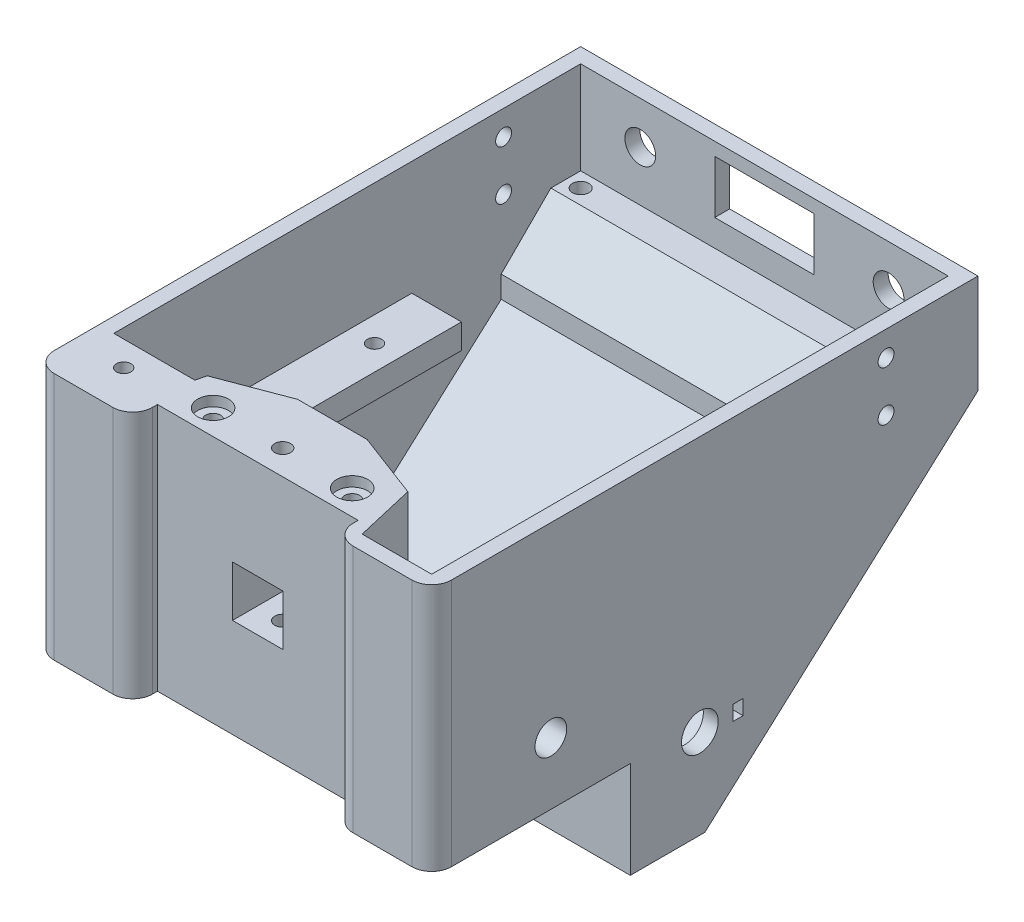
from build123d import *

# Parameters (mm, degrees)
BOSS_EXTRUDE1_DEPTH      = 80
SHELL1_T                 = -3
SKETCH3_W                = 46
SKETCH3_H                = 47
BOSS_EXTRUDE2_DEPTH      = 17
SKETCH4_W                = 10.2
SKETCH4_H                = 10.2
CUT_EXTRUDE1_DEPTH       = 20
SKETCH6_W                = 15
SKETCH6_H                = 12.8
CUT_EXTRUDE2_DEPTH       = 3
SKETCH7_W                = 40.4
SKETCH7_H                = 50
CUT_EXTRUDE3_DEPTH       = 5
FILLET1_R                = 4
CUT_EXTRUDE7_DEPTH       = 47
SKETCH13_R               = 1.5
CUT_EXTRUDE8_DEPTH       = 25
SKETCH14_R               = 3.1
CUT_EXTRUDE9_DEPTH       = 2
SKETCH17_W               = 45
SKETCH17_H               = 5
BOSS_EXTRUDE5_DEPTH      = 74
CUT_EXTRUDE10_REACH      = 126.093
SKETCH18_W               = 54
SKETCH18_H               = 45
CUT_EXTRUDE11_REACH      = 126.093
SKETCH19_R               = 1.45
BOSS_EXTRUDE6_DEPTH      = 47
SKETCH22_R               = 1.45
CUT_EXTRUDE12_DEPTH      = 135.415364765
CUT_EXTRUDE13_REACH      = 126.857
SKETCH24_R               = 3.7
SKETCH24_W               = 2
SKETCH24_H               = 3
BOSS_EXTRUDE7_DEPTH      = 74
SKETCH27_R               = 1.65
CUT_EXTRUDE14_DEPTH      = 10
CUT_EXTRUDE15_START      = -3
CUT_EXTRUDE15_DEPTH      = 32
CUT_EXTRUDE16_DEPTH      = 30
BOSS_EXTRUDE8_DEPTH      = 20
SKETCH31_R               = 1.5
CUT_EXTRUDE17_DEPTH      = 123.649786567
CUT_EXTRUDE18_DEPTH      = 15
CUT_EXTRUDE19_REACH      = 126.093
SKETCH33_W               = 10
SKETCH33_H               = 5
SKETCH34_R               = 1.6
CUT_EXTRUDE20_DEPTH      = 135.415364765
CUT_EXTRUDE22_DEPTH      = 14
CUT_EXTRUDE23_REACH      = 126.857
SKETCH37_R               = 3.2
SKETCH38_W               = 10
SKETCH38_H               = 18.980735551
SKETCH38_R               = 3.2
BOSS_EXTRUDE9_DEPTH      = 3
CUT_EXTRUDE24_REACH      = 124.956
SKETCH40_R               = 3.7
SKETCH40_W               = 2
SKETCH40_H               = 3
SKETCH41_R               = 1.6
CUT_EXTRUDE25_DEPTH      = 123.956316006
CUT_EXTRUDE25_DEPTH_BACK = 123.956316006
SKETCH43_W               = 20
SKETCH43_H               = 10.67
CUT_EXTRUDE26_DEPTH      = 3
CHAMFER1_SIZE            = 10
SKETCH44_R               = 3.1
CUT_EXTRUDE27_DEPTH      = 143.134986308


with BuildPart() as part:
    # Sketch2 → Boss-Extrude1 (new body)
    with BuildSketch(Plane(origin=(0, 0, 0), x_dir=(0, 0, -1), z_dir=(1, 0, 0))):
        Polygon((-27.320490368, 20.998248687), (-27.320490368, -29.001751313), (12.679509632, -29.001751313), (12.679509632, -48.511383538), (27.679509632, -48.511383538), (82.679509632, 0.998248687), (82.679509632, 20.998248687), align=None)
    extrude(amount=BOSS_EXTRUDE1_DEPTH)

    # Shell1
    shell1_openings = [part.faces().sort_by_distance(p)[0] for p in [
        (40, 20.998248687, -27.679509632),
    ]]
    offset(amount=SHELL1_T, openings=shell1_openings, kind=Kind.INTERSECTION)

    # Sketch3 → Boss-Extrude2 (add)
    with BuildSketch(Plane(origin=(0, 0, 24.320490368), x_dir=(-1, 0, 0), z_dir=(0, 0, -1))):
        with Locations((-40, -2.501751313)):
            Rectangle(SKETCH3_W, SKETCH3_H)
    extrude(amount=BOSS_EXTRUDE2_DEPTH)

    # Sketch4 → Cut-Extrude1 (cut)
    with BuildSketch(Plane.XY.offset(27.320490368)):
        with Locations((40, -4.001751313)):
            Rectangle(SKETCH4_W, SKETCH4_H)
    extrude(amount=-CUT_EXTRUDE1_DEPTH, mode=Mode.SUBTRACT)

    # Sketch6 → Cut-Extrude2 (cut)
    with BuildSketch(Plane.XZ.offset(29.001751313)):
        with Locations((51.5, 0.920490368)):
            Rectangle(SKETCH6_W, SKETCH6_H)
        with Locations((28.5, 0.920490368)):
            Rectangle(SKETCH6_W, SKETCH6_H)
    extrude(amount=-CUT_EXTRUDE2_DEPTH, mode=Mode.SUBTRACT)

    # Sketch7 → Cut-Extrude3 (cut)
    with BuildSketch(Plane.XY.offset(27.320490368)):
        with Locations((40, -4.001751313)):
            Rectangle(SKETCH7_W, SKETCH7_H)
    extrude(amount=-CUT_EXTRUDE3_DEPTH, mode=Mode.SUBTRACT)

    # Fillet1
    fillet1_edges = [part.edges().sort_by_distance(p)[0] for p in [
        (19.8, -4.001751313, 27.320490368),
        (60.2, -4.001751313, 27.320490368),
        (80, -4.001751313, 27.320490368),
        (0, -4.001751313, 27.320490368),
    ]]
    fillet(fillet1_edges, radius=FILLET1_R)

    # Sketch12 → Cut-Extrude7 (cut)
    with BuildSketch(Plane(origin=(0, 20.998248687, 0), x_dir=(1, 0, 0), z_dir=(0, 1, 0))):
        Polygon((33, -7.320490368), (19.8, -12.320490368), (17, -24.320490368), (17, -7.320490368), align=None)
        Polygon((47, -7.320490368), (63, -7.320490368), (63, -24.320490368), (60.2, -12.320490368), align=None)
    extrude(amount=-CUT_EXTRUDE7_DEPTH, mode=Mode.SUBTRACT)

    # Sketch13 → Cut-Extrude8 (cut)
    with BuildSketch(Plane(origin=(0, 20.998248687, 0), x_dir=(1, 0, 0), z_dir=(0, 1, 0))):
        with Locations(Location((26, -17.320490368, 0), (0, 0, 270))):
            Circle(SKETCH13_R)
        with Locations(Location((54, -17.320490368, 0), (0, 0, 270))):
            Circle(SKETCH13_R)
    extrude(amount=-CUT_EXTRUDE8_DEPTH, mode=Mode.SUBTRACT)

    # Sketch14 → Cut-Extrude9 (cut)
    with BuildSketch(Plane(origin=(0, 20.998248687, 0), x_dir=(1, 0, 0), z_dir=(0, 1, 0))):
        with Locations(Location((26, -17.320490368, 0), (0, 0, 270))):
            Circle(SKETCH14_R)
        with Locations(Location((54, -17.320490368, 0), (0, 0, 270))):
            Circle(SKETCH14_R)
    extrude(amount=-CUT_EXTRUDE9_DEPTH, mode=Mode.SUBTRACT)

    # Sketch17 → Boss-Extrude5 (add)
    with BuildSketch(Plane.ZY.offset(-77)):
        with Locations((-23.179509632, -4.501751313)):
            Rectangle(SKETCH17_W, SKETCH17_H)
    extrude(amount=BOSS_EXTRUDE5_DEPTH)

    # Sketch18 → Cut-Extrude10 (cut, up to next)
    with BuildSketch(Plane(origin=(0, -2.001751313, 0), x_dir=(1, 0, 0), z_dir=(0, 1, 0)), mode=Mode.PRIVATE) as cut_extrude10_sk1:
        with Locations((40, 23.179509632)):
            Rectangle(SKETCH18_W, SKETCH18_H)
    cut_extrude10_tool1 = extrude(cut_extrude10_sk1.sketch, amount=-CUT_EXTRUDE10_REACH, mode=Mode.PRIVATE) & part.part
    add(cut_extrude10_tool1.solids().sort_by_distance((40, -2.001751, -23.17951))[0], mode=Mode.SUBTRACT)

    # Sketch19 → Cut-Extrude11 (cut, up to next)
    with BuildSketch(Plane(origin=(0, -2.001751313, 0), x_dir=(1, 0, 0), z_dir=(0, 1, 0)), mode=Mode.PRIVATE) as cut_extrude11_sk1:
        with Locations(Location((72, 37.179509632, 0), (0, 0, 270))):
            Circle(SKETCH19_R)
    cut_extrude11_tool1 = extrude(cut_extrude11_sk1.sketch, amount=-CUT_EXTRUDE11_REACH, mode=Mode.PRIVATE) & part.part
    # Sketch19 → Cut-Extrude11 (cut, up to next)
    with BuildSketch(Plane(origin=(0, -2.001751313, 0), x_dir=(1, 0, 0), z_dir=(0, 1, 0)), mode=Mode.PRIVATE) as cut_extrude11_sk2:
        with Locations(Location((72, 6.179509632, 0), (0, 0, 270))):
            Circle(SKETCH19_R)
    cut_extrude11_tool2 = extrude(cut_extrude11_sk2.sketch, amount=-CUT_EXTRUDE11_REACH, mode=Mode.PRIVATE) & part.part
    # Sketch19 → Cut-Extrude11 (cut, up to next)
    with BuildSketch(Plane(origin=(0, -2.001751313, 0), x_dir=(1, 0, 0), z_dir=(0, 1, 0)), mode=Mode.PRIVATE) as cut_extrude11_sk3:
        with Locations(Location((8, 33.179509632, 0), (0, 0, 270))):
            Circle(SKETCH19_R)
    cut_extrude11_tool3 = extrude(cut_extrude11_sk3.sketch, amount=-CUT_EXTRUDE11_REACH, mode=Mode.PRIVATE) & part.part
    # Sketch19 → Cut-Extrude11 (cut, up to next)
    with BuildSketch(Plane(origin=(0, -2.001751313, 0), x_dir=(1, 0, 0), z_dir=(0, 1, 0)), mode=Mode.PRIVATE) as cut_extrude11_sk4:
        with Locations(Location((8, 6.179509632, 0), (0, 0, 270))):
            Circle(SKETCH19_R)
    cut_extrude11_tool4 = extrude(cut_extrude11_sk4.sketch, amount=-CUT_EXTRUDE11_REACH, mode=Mode.PRIVATE) & part.part
    add(cut_extrude11_tool1.solids().sort_by_distance((72, -2.001751, -37.17951))[0], mode=Mode.SUBTRACT)
    add(cut_extrude11_tool2.solids().sort_by_distance((72, -2.001751, -6.17951))[0], mode=Mode.SUBTRACT)
    add(cut_extrude11_tool3.solids().sort_by_distance((8, -2.001751, -33.17951))[0], mode=Mode.SUBTRACT)
    add(cut_extrude11_tool4.solids().sort_by_distance((8, -2.001751, -6.17951))[0], mode=Mode.SUBTRACT)

    # Sketch21 → Boss-Extrude6 (add)
    with BuildSketch(Plane(origin=(0, -26.001751313, 0), x_dir=(1, 0, 0), z_dir=(0, 1, 0))):
        Polygon((3, -24.320490368), (3, -14.320490368), (19.333333333, -14.320490368), (17, -24.320490368), align=None)
    extrude(amount=BOSS_EXTRUDE6_DEPTH)

    # Sketch22 → Cut-Extrude12 (cut, through all)
    with BuildSketch(Plane(origin=(0, 20.998248687, 0), x_dir=(1, 0, 0), z_dir=(0, 1, 0))):
        with Locations(Location((10, -19.320490368, 0), (0, 0, 270))):
            Circle(SKETCH22_R)
    extrude(amount=-CUT_EXTRUDE12_DEPTH, mode=Mode.SUBTRACT)

    # Sketch24 → Cut-Extrude13 (cut, up to next)
    with BuildSketch(Plane(origin=(80, 0, 0), x_dir=(0, 0, -1), z_dir=(1, 0, 0)), mode=Mode.PRIVATE) as cut_extrude13_sk1:
        with Locations((26.679509632, -30.511383538)):
            Circle(SKETCH24_R)
    cut_extrude13_tool1 = extrude(cut_extrude13_sk1.sketch, amount=-CUT_EXTRUDE13_REACH, mode=Mode.PRIVATE) & part.part
    # Sketch24 → Cut-Extrude13 (cut, up to next)
    with BuildSketch(Plane(origin=(80, 0, 0), x_dir=(0, 0, -1), z_dir=(1, 0, 0)), mode=Mode.PRIVATE) as cut_extrude13_sk2:
        with Locations((34.379509632, -30.511383538)):
            Rectangle(SKETCH24_W, SKETCH24_H)
    cut_extrude13_tool2 = extrude(cut_extrude13_sk2.sketch, amount=-CUT_EXTRUDE13_REACH, mode=Mode.PRIVATE) & part.part
    add(cut_extrude13_tool1.solids().sort_by_distance((80, -30.511384, -26.67951))[0], mode=Mode.SUBTRACT)
    add(cut_extrude13_tool2.solids().sort_by_distance((80, -30.511384, -34.37951))[0], mode=Mode.SUBTRACT)

    # Sketch26 → Boss-Extrude7 (add)
    with BuildSketch(Plane(origin=(3, 0, 0), x_dir=(0, 0, -1), z_dir=(1, 0, 0))):
        Polygon((79.679509632, 2.334161996), (63.679509632, 2.334161996), (63.679509632, -12.068640106), align=None)
    extrude(amount=BOSS_EXTRUDE7_DEPTH)

    # Sketch27 → Cut-Extrude14 (cut)
    with BuildSketch(Plane(origin=(0, 2.334161996, 0), x_dir=(1, 0, 0), z_dir=(0, 1, 0))):
        with Locations(Location((6, 76.679509632, 0), (0, 0, 270))):
            Circle(SKETCH27_R)
        with Locations(Location((74, 76.679509632, 0), (0, 0, 270))):
            Circle(SKETCH27_R)
    extrude(amount=-CUT_EXTRUDE14_DEPTH, mode=Mode.SUBTRACT)

    # Sketch28 → Cut-Extrude15 (cut)
    with BuildSketch(Plane(origin=(0, 2.334161996, 0), x_dir=(1, 0, 0), z_dir=(0, 1, 0)).offset(CUT_EXTRUDE15_START)):
        Polygon((74, 79.929509632), (71.185417438, 78.304509632), (71.185417438, 75.054509632), (74, 73.429509632), (76.814582562, 75.054509632), (76.814582562, 78.304509632), align=None)
        Polygon((6, 73.429509632), (8.814582562, 75.054509632), (8.814582562, 78.304509632), (6, 79.929509632), (3.185417438, 78.304509632), (3.185417438, 75.054509632), align=None)
    extrude(amount=-CUT_EXTRUDE15_DEPTH, mode=Mode.SUBTRACT)

    # Sketch29 → Cut-Extrude16 (cut)
    with BuildSketch(Plane.XZ.offset(29.001751313)):
        Polygon((7.185417438, 17.695490368), (10, 16.070490368), (12.814582562, 17.695490368), (12.814582562, 20.945490368), (10, 22.570490368), (7.185417438, 20.945490368), align=None)
    extrude(amount=-CUT_EXTRUDE16_DEPTH, mode=Mode.SUBTRACT)

    # Sketch30 → Boss-Extrude8 (add)
    with BuildSketch(Plane(origin=(0, -26.001751313, 0), x_dir=(1, 0, 0), z_dir=(0, 1, 0))):
        Polygon((77, -24.320490368), (63, -24.320490368), (60.2, -12.320490368), (77, -12.320490368), align=None)
    extrude(amount=BOSS_EXTRUDE8_DEPTH)

    # Sketch31 → Cut-Extrude17 (cut, through all)
    with BuildSketch(Plane(origin=(0, -6.001751313, 0), x_dir=(1, 0, 0), z_dir=(0, 1, 0))):
        with Locations(Location((72, -21.320490368, 0), (0, 0, 270))):
            Circle(SKETCH31_R)
    extrude(amount=-CUT_EXTRUDE17_DEPTH, mode=Mode.SUBTRACT)

    # Sketch32 → Cut-Extrude18 (cut)
    with BuildSketch(Plane.XZ.offset(29.001751313)):
        Polygon((72, 24.570490368), (69.185417438, 22.945490368), (69.185417438, 19.695490368), (72, 18.070490368), (74.814582562, 19.695490368), (74.814582562, 22.945490368), align=None)
    extrude(amount=-CUT_EXTRUDE18_DEPTH, mode=Mode.SUBTRACT)

    # Sketch33 → Cut-Extrude19 (cut, up to next)
    with BuildSketch(Plane(origin=(0, -2.001751313, 0), x_dir=(1, 0, 0), z_dir=(0, 1, 0)), mode=Mode.PRIVATE) as cut_extrude19_sk1:
        with Locations((72, 43.179509632)):
            Rectangle(SKETCH33_W, SKETCH33_H)
    cut_extrude19_tool1 = extrude(cut_extrude19_sk1.sketch, amount=-CUT_EXTRUDE19_REACH, mode=Mode.PRIVATE) & part.part
    add(cut_extrude19_tool1.solids().sort_by_distance((72, -2.001751, -43.17951))[0], mode=Mode.SUBTRACT)

    # Sketch34 → Cut-Extrude20 (cut, through all)
    with BuildSketch(Plane(origin=(0, 20.998248687, 0), x_dir=(1, 0, 0), z_dir=(0, 1, 0))):
        with Locations(Location((40, -17.320490368, 0), (0, 0, 270))):
            Circle(SKETCH34_R)
    extrude(amount=-CUT_EXTRUDE20_DEPTH, mode=Mode.SUBTRACT)

    # Sketch36 → Cut-Extrude22 (cut)
    with BuildSketch(Plane.XZ.offset(29.001751313)):
        Polygon((38.375, 20.13507293), (36.75, 17.320490368), (38.375, 14.505907805), (41.625, 14.505907805), (43.25, 17.320490368), (41.625, 20.13507293), align=None)
    extrude(amount=-CUT_EXTRUDE22_DEPTH, mode=Mode.SUBTRACT)

    # Sketch37 → Cut-Extrude23 (cut, up to next)
    with BuildSketch(Plane(origin=(80, 0, 0), x_dir=(0, 0, -1), z_dir=(1, 0, 0)), mode=Mode.PRIVATE) as cut_extrude23_sk1:
        with Locations((-3.320490368, -16.511383538)):
            Circle(SKETCH37_R)
    cut_extrude23_tool1 = extrude(cut_extrude23_sk1.sketch, amount=-CUT_EXTRUDE23_REACH, mode=Mode.PRIVATE) & part.part
    add(cut_extrude23_tool1.solids().sort_by_distance((80, -16.511384, 3.32049))[0], mode=Mode.SUBTRACT)

    # Sketch38 → Boss-Extrude9 (add)
    with BuildSketch(Plane.ZY.offset(-77)):
        with Locations((3.320490368, -16.511383538)):
            Rectangle(SKETCH38_W, SKETCH38_H)
        with Locations(Location((3.320490368, -16.511383538, 0), (0, 0, 180))):
            Circle(SKETCH38_R, mode=Mode.SUBTRACT)
    extrude(amount=BOSS_EXTRUDE9_DEPTH)

    # Sketch40 → Cut-Extrude24 (cut, up to next)
    with BuildSketch(Plane(origin=(3, 0, 0), x_dir=(0, 0, -1), z_dir=(1, 0, 0)), mode=Mode.PRIVATE) as cut_extrude24_sk1:
        with Locations((26.679509632, -30.511383538)):
            Circle(SKETCH40_R)
    cut_extrude24_tool1 = extrude(cut_extrude24_sk1.sketch, amount=-CUT_EXTRUDE24_REACH, mode=Mode.PRIVATE) & part.part
    # Sketch40 → Cut-Extrude24 (cut, up to next)
    with BuildSketch(Plane(origin=(3, 0, 0), x_dir=(0, 0, -1), z_dir=(1, 0, 0)), mode=Mode.PRIVATE) as cut_extrude24_sk2:
        with Locations((18.979509632, -30.511383538)):
            Rectangle(SKETCH40_W, SKETCH40_H)
    cut_extrude24_tool2 = extrude(cut_extrude24_sk2.sketch, amount=-CUT_EXTRUDE24_REACH, mode=Mode.PRIVATE) & part.part
    add(cut_extrude24_tool1.solids().sort_by_distance((3, -30.511384, -26.67951))[0], mode=Mode.SUBTRACT)
    add(cut_extrude24_tool2.solids().sort_by_distance((3, -30.511384, -18.97951))[0], mode=Mode.SUBTRACT)

    # Sketch41 → Cut-Extrude25 (cut, two sides)
    with BuildSketch(Plane.ZY.offset(-77)) as cut_extrude25_sk:
        with Locations((-64.162210742, 15.998248687)):
            Circle(SKETCH41_R)
        with Locations((-64.162210742, 5.998248687)):
            Circle(SKETCH41_R)
    extrude(amount=CUT_EXTRUDE25_DEPTH, mode=Mode.SUBTRACT)
    extrude(cut_extrude25_sk.sketch, amount=-CUT_EXTRUDE25_DEPTH_BACK, mode=Mode.SUBTRACT)

    # Sketch43 → Cut-Extrude26 (cut)
    with BuildSketch(Plane.XY.offset(-79.679509632)):
        with Locations((40, 13.033248687)):
            Rectangle(SKETCH43_W, SKETCH43_H)
    extrude(amount=-CUT_EXTRUDE26_DEPTH, mode=Mode.SUBTRACT)

    # Chamfer1
    chamfer1_edges = [part.edges().sort_by_distance(p)[0] for p in [
        (40, 2.334161996, -63.679509632),
    ]]
    chamfer(chamfer1_edges, length=CHAMFER1_SIZE)

    # Sketch44 → Cut-Extrude27 (cut, through all)
    with BuildSketch(Plane.XY.offset(-79.679509632)):
        with Locations((65, 12.468248687)):
            Circle(SKETCH44_R)
        with Locations((15, 12.468248687)):
            Circle(SKETCH44_R)
    extrude(amount=-CUT_EXTRUDE27_DEPTH, mode=Mode.SUBTRACT)


solid = part.part
